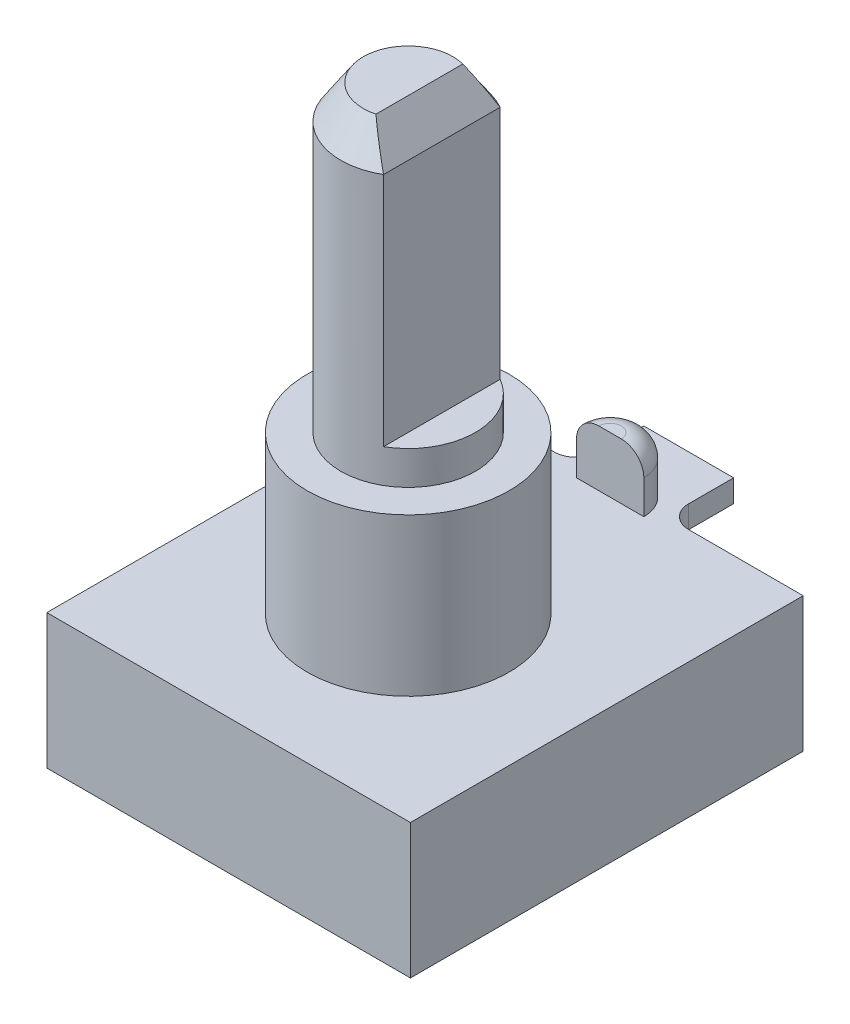
from build123d import *

# Parameters (mm, degrees)
SKETCH1_W           = 16.2
SKETCH1_H           = 17.5
BOSS_EXTRUDE1_DEPTH = 6
SKETCH2_W           = 12
SKETCH2_H           = 12
BOSS_EXTRUDE2_DEPTH = 1.5
SKETCH3_R           = 4.5
BOSS_EXTRUDE3_DEPTH = 7
SKETCH4_R           = 3
BOSS_EXTRUDE4_DEPTH = 13.5
CUT_EXTRUDE1_DEPTH  = 12
SKETCH6_W           = 4
SKETCH6_H           = 1
BOSS_EXTRUDE5_DEPTH = 3
FILLET1_R           = 1
CHAMFER1_SIZE       = 1.5
CHAMFER1_SIZE2      = 1
CHAMFER2_SIZE       = 1
CHAMFER2_SIZE2      = 1.5
BOSS_EXTRUDE6_DEPTH = 2.5
FILLET2_R           = 1


with BuildPart() as part:
    # Sketch1 → Boss-Extrude1 (new body)
    with BuildSketch(Plane(origin=(0, 0, 0), x_dir=(1, 0, 0), z_dir=(0, 1, 0))):
        Rectangle(SKETCH1_W, SKETCH1_H)
    extrude(amount=BOSS_EXTRUDE1_DEPTH)

    # Sketch2 → Boss-Extrude2 (add)
    with BuildSketch(Plane.XZ):
        Rectangle(SKETCH2_W, SKETCH2_H)
    extrude(amount=BOSS_EXTRUDE2_DEPTH)

    # Sketch3 → Boss-Extrude3 (add)
    with BuildSketch(Plane(origin=(0, 6, 0), x_dir=(1, 0, 0), z_dir=(0, 1, 0))):
        with Locations((0, -0.75)):
            Circle(SKETCH3_R)
    extrude(amount=BOSS_EXTRUDE3_DEPTH)

    # Sketch4 → Boss-Extrude4 (add)
    with BuildSketch(Plane(origin=(0, 13, 0), x_dir=(1, 0, 0), z_dir=(0, 1, 0))):
        with Locations((0, -0.75)):
            Circle(SKETCH4_R)
    extrude(amount=BOSS_EXTRUDE4_DEPTH)

    # Sketch5 → Cut-Extrude1 (cut)
    with BuildSketch(Plane(origin=(0, 26.5, 0), x_dir=(1, 0, 0), z_dir=(0, 1, 0))):
        with BuildLine():
            ThreePointArc((3, -0.75), (2.598076211, 0.75), (1.5, 1.848076211))
            Line((1.5, 1.848076211), (1.5, -3.348076211))
            ThreePointArc((1.5, -3.348076211), (2.598076211, -2.25), (3, -0.75))
        make_face()
    extrude(amount=-CUT_EXTRUDE1_DEPTH, mode=Mode.SUBTRACT)

    # Sketch6 → Boss-Extrude5 (add)
    with BuildSketch(Plane(origin=(0, 0, -8.75), x_dir=(-1, 0, 0), z_dir=(0, 0, -1))):
        with Locations((0, 5.5)):
            Rectangle(SKETCH6_W, SKETCH6_H)
    extrude(amount=BOSS_EXTRUDE5_DEPTH)

    # Fillet1
    fillet1_edges = [part.edges().sort_by_distance(p)[0] for p in [
        (-2, 5.5, -8.75),
        (2, 5.5, -8.75),
    ]]
    fillet(fillet1_edges, radius=FILLET1_R)

    # Chamfer1
    chamfer1_edges = [part.edges().sort_by_distance(p)[0] for p in [
        (-3, 26.5, 0.75),
    ]]
    chamfer1_side = [part.faces().sort_by_distance(p)[0] for p in [
        (-3, 19.75, 0.75),
    ]]
    chamfer(chamfer1_edges, length=CHAMFER1_SIZE, length2=CHAMFER1_SIZE2, reference=chamfer1_side[0])

    # Chamfer2
    chamfer2_edges = [part.edges().sort_by_distance(p)[0] for p in [
        (1.5, 26.5, 0.75),
    ]]
    chamfer2_side = [part.faces().sort_by_distance(p)[0] for p in [
        (-0.132366073, 26.5, 0.75),
    ]]
    chamfer(chamfer2_edges, length=CHAMFER2_SIZE, length2=CHAMFER2_SIZE2, reference=chamfer2_side[0])

    # Sketch7 → Boss-Extrude6 (add)
    with BuildSketch(Plane(origin=(0, 6, 0), x_dir=(1, 0, 0), z_dir=(0, 1, 0))):
        with BuildLine():
            Line((-1.5, 8.25), (1.5, 8.25))
            ThreePointArc((1.5, 8.25), (0, 9.75), (-1.5, 8.25))
        make_face()
    extrude(amount=BOSS_EXTRUDE6_DEPTH)

    # Fillet2
    fillet2_edges = [part.edges().sort_by_distance(p)[0] for p in [
        (0, 8.5, -9.75),
    ]]
    fillet(fillet2_edges, radius=FILLET2_R)


solid = part.part
